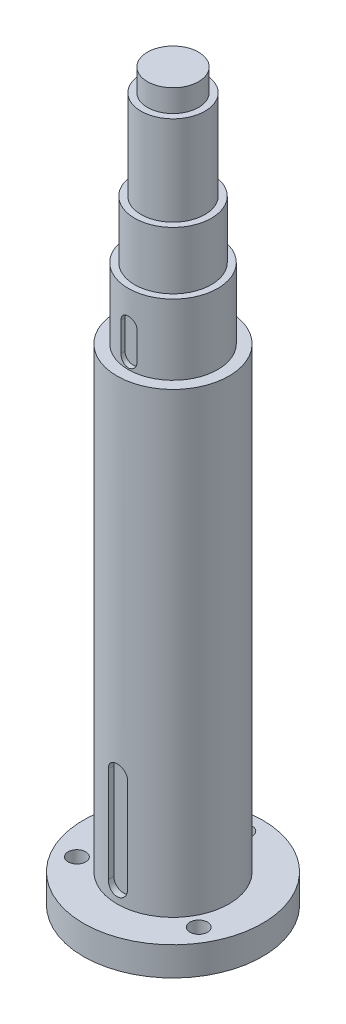
from build123d import *

# Parameters (mm, degrees)
CUT_EXTRUDE1_DEPTH = 2
CUT_EXTRUDE2_DEPTH = 1.5
SKETCH7_R          = 2.75
CUT_EXTRUDE3_DEPTH = 9
SKETCH8_R          = 4.5
CUT_EXTRUDE4_DEPTH = 5
CIRPATTERN1_COUNT  = 3
CIRPATTERN2_COUNT  = 3


with BuildPart() as part:
    # Sketch1 → Revolve1 (revolve)
    with BuildSketch(Plane.XY):
        Polygon((0, 0), (28, 0), (28, 9), (17.5, 9), (17.5, 152), (14, 152), (14, 174), (12, 174), (12, 192), (10, 192), (10, 220), (8, 220), (8, 227), (0, 227), align=None)
    revolve(axis=Axis((0, 340.077659461, 0), (0, -1, 0)))

    # Sketch2 → Cut-Extrude1 (cut)
    with BuildSketch(Plane.XY.offset(17.5)):
        with BuildLine():
            Line((3, 44), (3, 14))
            ThreePointArc((3, 14), (0, 11), (-3, 14))
            Line((-3, 14), (-3, 44))
            ThreePointArc((-3, 44), (0, 47), (3, 44))
        make_face()
    extrude(amount=-CUT_EXTRUDE1_DEPTH, mode=Mode.SUBTRACT)

    # Sketch3 → Cut-Extrude2 (cut)
    with BuildSketch(Plane.XY.offset(14)):
        with BuildLine():
            Line((2.5, 164), (2.5, 155))
            ThreePointArc((2.5, 155), (0, 152.5), (-2.5, 155))
            Line((-2.5, 155), (-2.5, 164))
            ThreePointArc((-2.5, 164), (0, 166.5), (2.5, 164))
        make_face()
    extrude(amount=-CUT_EXTRUDE2_DEPTH, mode=Mode.SUBTRACT)

    # Sketch7 → Cut-Extrude3 (cut)
    with BuildSketch(Plane.XZ):
        with Locations((0, -22)):
            Circle(SKETCH7_R)
    cut_extrude3 = extrude(amount=-CUT_EXTRUDE3_DEPTH, mode=Mode.SUBTRACT)

    # Sketch8 → Cut-Extrude4 (cut)
    with BuildSketch(Plane.XZ):
        with Locations((0, -22)):
            Circle(SKETCH8_R)
    cut_extrude4 = extrude(amount=-CUT_EXTRUDE4_DEPTH, mode=Mode.SUBTRACT)

    # CirPattern1: Cut-Extrude3 ×3 about axis
    cirpattern1_axis = Axis((0, 0, 0), (0, 1, 0))
    for i in range(1, CIRPATTERN1_COUNT):
        add(cut_extrude3.rotate(cirpattern1_axis, i * 360 / CIRPATTERN1_COUNT), mode=Mode.SUBTRACT)

    # CirPattern2: Cut-Extrude4 ×3 about axis
    cirpattern2_axis = Axis((0, 0, 0), (0, 1, 0))
    for i in range(1, CIRPATTERN2_COUNT):
        add(cut_extrude4.rotate(cirpattern2_axis, i * 360 / CIRPATTERN2_COUNT), mode=Mode.SUBTRACT)


solid = part.part
